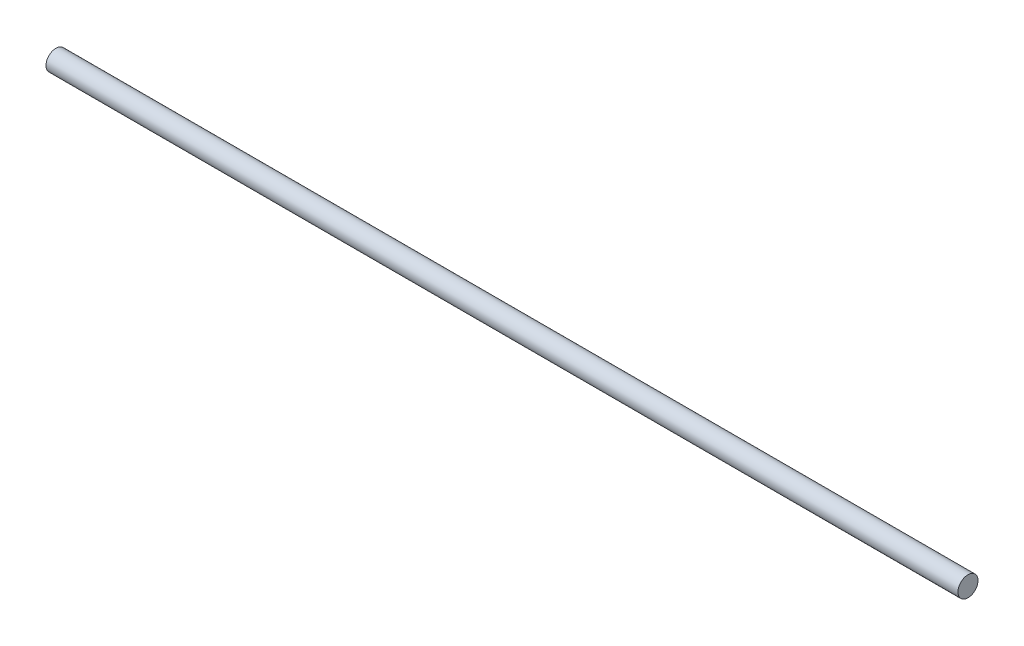
from build123d import *

# Parameters (mm, degrees)
SKETCH1_R           = 5.588
BOSS_EXTRUDE1_DEPTH = 508


with BuildPart() as part:
    # Sketch1 → Boss-Extrude1 (new body)
    with BuildSketch(Plane(origin=(0, 0, 0), x_dir=(0, 0, -1), z_dir=(1, 0, 0))):
        Circle(SKETCH1_R)
    extrude(amount=BOSS_EXTRUDE1_DEPTH)


solid = part.part
